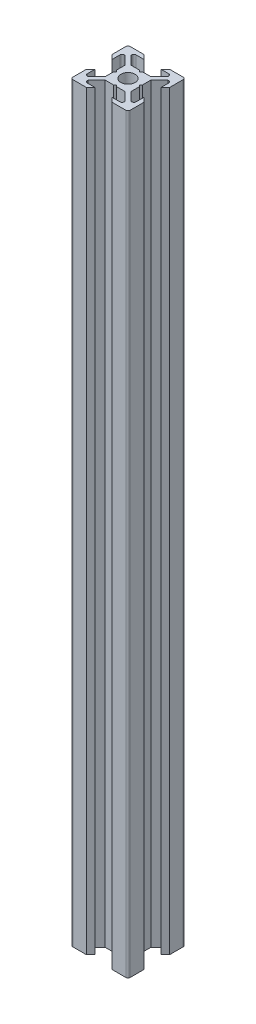
from build123d import *

# Parameters (mm, degrees)
ESQUISSE1_R      = 2.5
EXTRUSION1_DEPTH = 262
CONG_1_R         = 0.75


with BuildPart() as part:
    # Esquisse1 → Extrusion1 (new body)
    with BuildSketch(Plane(origin=(0, 0, 0), x_dir=(1, 0, 0), z_dir=(0, 1, 0))):
        Polygon((0, 4), (-0.5, 4.5), (-3.439339828, 4.5), (-6.439339828, 7.5), (-6.439339828, 8.5), (-3, 8.5), (-4.5, 10), (-10, 10), (-10, 4.5), (-8.5, 3), (-8.5, 6.439339828), (-7.5, 6.439339828), (-4.5, 3.439339828), (-4.5, 0.5), (-4, 0), (-4.5, -0.5), (-4.5, -3.439339828), (-7.5, -6.439339828), (-8.5, -6.439339828), (-8.5, -3), (-10, -4.5), (-10, -10), (-4.5, -10), (-3, -8.5), (-6.439339828, -8.5), (-6.439339828, -7.5), (-3.439339828, -4.5), (-0.5, -4.5), (0, -4), (0.5, -4.5), (3.439339828, -4.5), (6.439339828, -7.5), (6.439339828, -8.5), (3, -8.5), (4.5, -10), (10, -10), (10, -4.5), (8.5, -3), (8.5, -6.439339828), (7.5, -6.439339828), (4.5, -3.439339828), (4.5, -0.5), (4, 0), (4.5, 0.5), (4.5, 3.439339828), (7.5, 6.439339828), (8.5, 6.439339828), (8.5, 3), (10, 4.5), (10, 10), (4.5, 10), (3, 8.5), (6.439339828, 8.5), (6.439339828, 7.5), (3.439339828, 4.5), (0.5, 4.5), align=None)
        Circle(ESQUISSE1_R, mode=Mode.SUBTRACT)
    extrude(amount=EXTRUSION1_DEPTH)

    # Congé1
    cong_1_edges = [part.edges().sort_by_distance(p)[0] for p in [
        (6.439339828, 131, -8.5),
        (10, 131, -10),
        (8.5, 131, -6.439339828),
        (8.5, 131, 6.439339828),
        (10, 131, 10),
        (6.439339828, 131, 8.5),
        (-6.439339828, 131, 8.5),
        (-10, 131, 10),
        (-8.5, 131, 6.439339828),
        (-8.5, 131, -6.439339828),
        (-10, 131, -10),
        (-6.439339828, 131, -8.5),
    ]]
    fillet(cong_1_edges, radius=CONG_1_R)


solid = part.part
